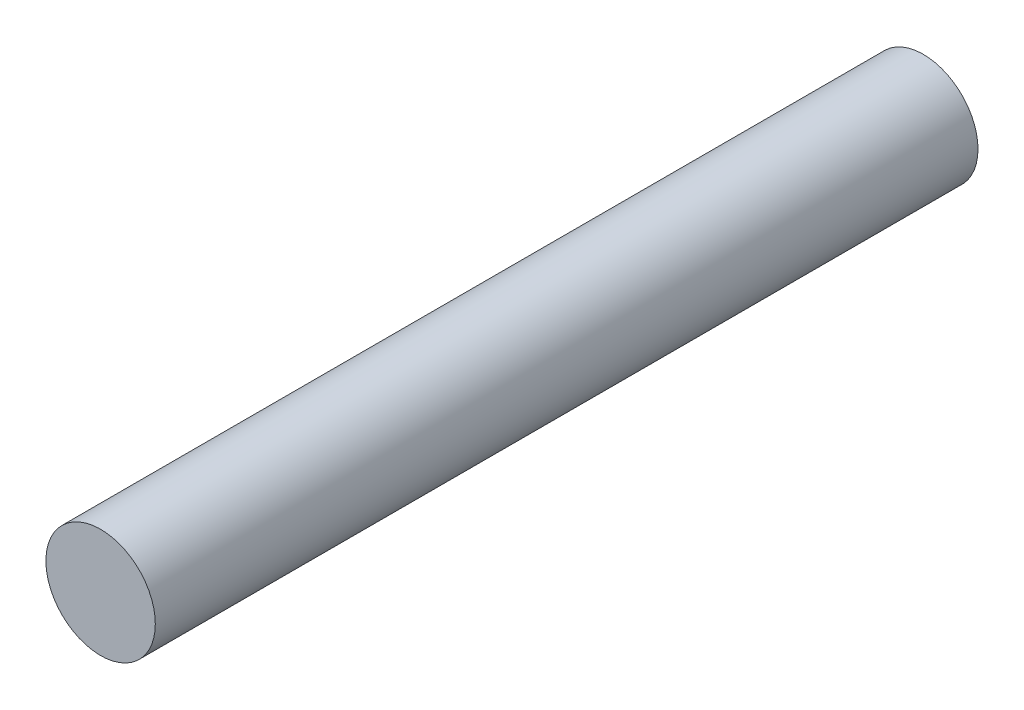
from build123d import *

# Parameters (mm, degrees)
SKETCH1_R           = 3.99
BOSS_EXTRUDE1_DEPTH = 60


with BuildPart() as part:
    # Sketch1 → Boss-Extrude1 (new body)
    with BuildSketch(Plane.XY):
        with Locations((-7.804735568, 1.216001185)):
            Circle(SKETCH1_R)
    extrude(amount=BOSS_EXTRUDE1_DEPTH)


solid = part.part
